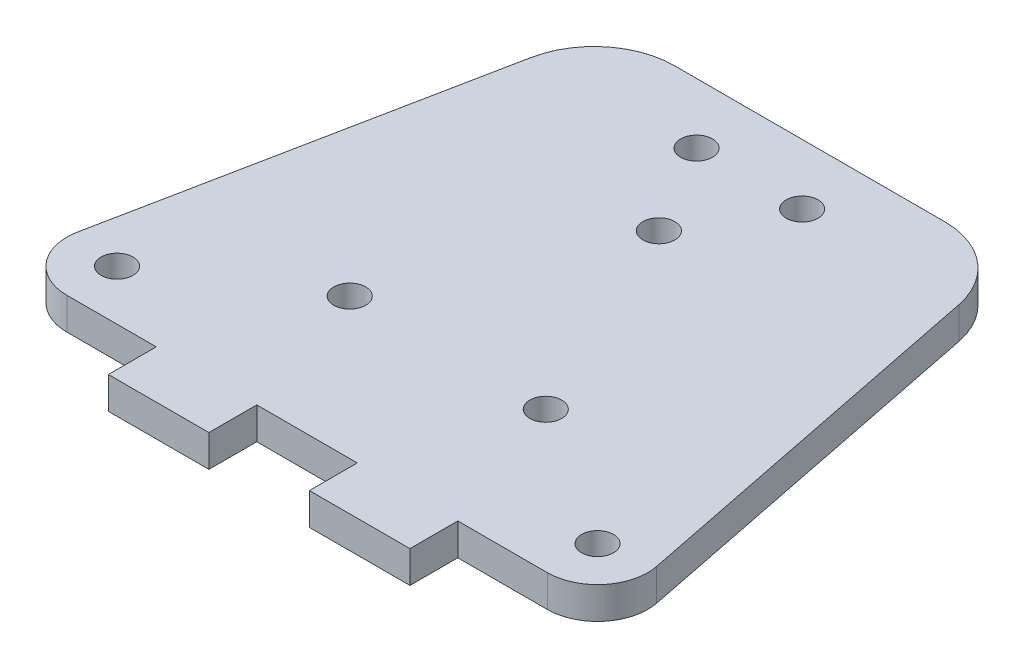
from build123d import *

# Parameters (mm, degrees)
CROQUIS1_R              = 1.5875
SALIENTE_EXTRUIR1_DEPTH = 3.175
CROQUIS2_R              = 1.5875
CORTAR_EXTRUIR1_DEPTH   = 3.175
CROQUIS3_W              = 10
CROQUIS3_H              = 4.7625
SALIENTE_EXTRUIR2_DEPTH = 3.175


with BuildPart() as part:
    # Croquis1 → Saliente-Extruir1 (new body)
    with BuildSketch(Plane(origin=(0, 0, 0), x_dir=(1, 0, 0), z_dir=(0, 1, 0))):
        with BuildLine():
            Line((8.713785816, 43.568929081), (0, 0))
            Line((0, 0), (60, 0))
            Line((60, 0), (51.286214184, 43.568929081))
            ThreePointArc((51.286214184, 43.568929081), (48.513480023, 48.186737131), (43.441568778, 50))
            Line((43.441568778, 50), (16.558431222, 50))
            ThreePointArc((16.558431222, 50), (11.486519977, 48.186737131), (8.713785816, 43.568929081))
        make_face()
        with Locations((39.75, 14)):
            Circle(CROQUIS1_R, mode=Mode.SUBTRACT)
        with Locations((20.25, 14)):
            Circle(CROQUIS1_R, mode=Mode.SUBTRACT)
        with Locations((24.75, 44)):
            Circle(CROQUIS1_R, mode=Mode.SUBTRACT)
        with Locations((35.25, 44)):
            Circle(CROQUIS1_R, mode=Mode.SUBTRACT)
    extrude(amount=SALIENTE_EXTRUIR1_DEPTH)

    # Croquis2 → Cortar-Extruir1 (cut)
    with BuildSketch(Plane(origin=(0, 3.175, 0), x_dir=(1, 0, 0), z_dir=(0, 1, 0))):
        with Locations((30, 35)):
            Circle(CROQUIS2_R)
        with Locations((6.099019514, 5)):
            Circle(CROQUIS2_R)
        with Locations((53.900980486, 5)):
            Circle(CROQUIS2_R)
        with BuildLine():
            Line((53.900980486, 0), (60, 0))
            Line((60, 0), (58.803883865, 5.980580676))
            ThreePointArc((58.803883865, 5.980580676), (57.767691193, 1.830055472), (53.900980486, 0))
        make_face()
        with BuildLine():
            Line((1.196116135, 5.980580676), (0, 0))
            Line((0, 0), (6.099019514, 0))
            ThreePointArc((6.099019514, 0), (2.232308807, 1.830055472), (1.196116135, 5.980580676))
        make_face()
    extrude(amount=-CORTAR_EXTRUIR1_DEPTH, mode=Mode.SUBTRACT)

    # Croquis3 → Saliente-Extruir2 (add)
    with BuildSketch(Plane(origin=(0, 3.175, 0), x_dir=(1, 0, 0), z_dir=(0, 1, 0))):
        with Locations((20, -2.38125)):
            Rectangle(CROQUIS3_W, CROQUIS3_H)
        with Locations((40, -2.38125)):
            Rectangle(CROQUIS3_W, CROQUIS3_H)
    extrude(amount=-SALIENTE_EXTRUIR2_DEPTH)


solid = part.part
